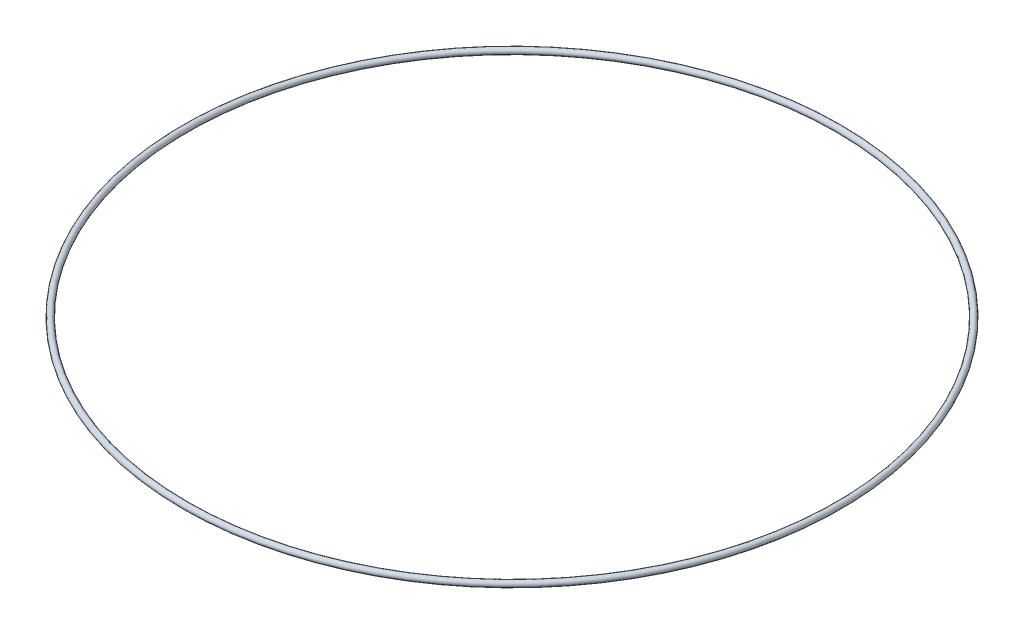
from build123d import *

# Parameters (mm, degrees)
SKETCH1_R = 0.889


with BuildPart() as part:
    # Sketch1 → Revolve1 (revolve)
    with BuildSketch(Plane.XY):
        with Locations((96.52, 0)):
            Circle(SKETCH1_R)
    revolve(axis=Axis((0, 0, 0), (0, 1, 0)))


solid = part.part
